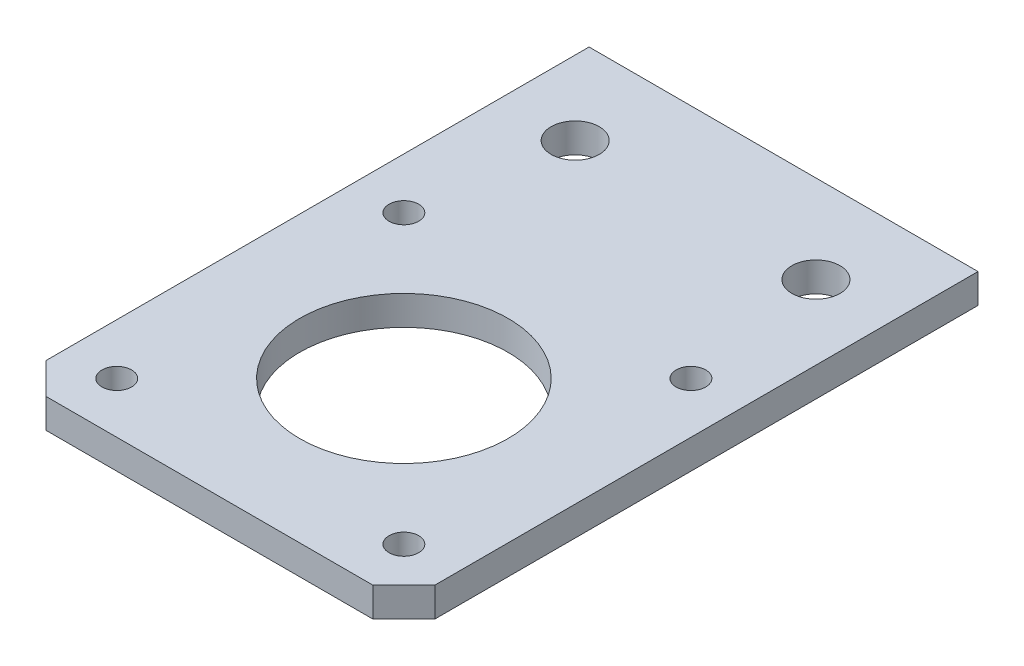
from build123d import *

# Parameters (mm, degrees)
SKETCH1_R           = 2.6
SKETCH1_R_2         = 1.6
SKETCH1_R_3         = 11.25
BOSS_EXTRUDE1_DEPTH = 3.175


with BuildPart() as part:
    # Sketch1 → Boss-Extrude1 (new body)
    with BuildSketch(Plane(origin=(0, 0, 0), x_dir=(1, 0, 0), z_dir=(0, 1, 0))):
        Polygon((21, 41), (-21, 41), (-21, 17.645), (-17.645, 21), (17.645, 21), (21, 17.645), align=None)
        with Locations((-13, 31.5)):
            Circle(SKETCH1_R, mode=Mode.SUBTRACT)
        with Locations((13, 31.5)):
            Circle(SKETCH1_R, mode=Mode.SUBTRACT)
        Polygon((-21, -17.645), (-21, 17.645), (-17.645, 21), (17.645, 21), (21, 17.645), (21, -17.645), (17.645, -21), (-17.645, -21), align=None)
        with Locations((15.5, -15.5)):
            Circle(SKETCH1_R_2, mode=Mode.SUBTRACT)
        with Locations((15.5, 15.5)):
            Circle(SKETCH1_R_2, mode=Mode.SUBTRACT)
        with Locations((-15.5, 15.5)):
            Circle(SKETCH1_R_2, mode=Mode.SUBTRACT)
        with Locations((-15.5, -15.5)):
            Circle(SKETCH1_R_2, mode=Mode.SUBTRACT)
        Circle(SKETCH1_R_3, mode=Mode.SUBTRACT)
    extrude(amount=BOSS_EXTRUDE1_DEPTH)


solid = part.part
